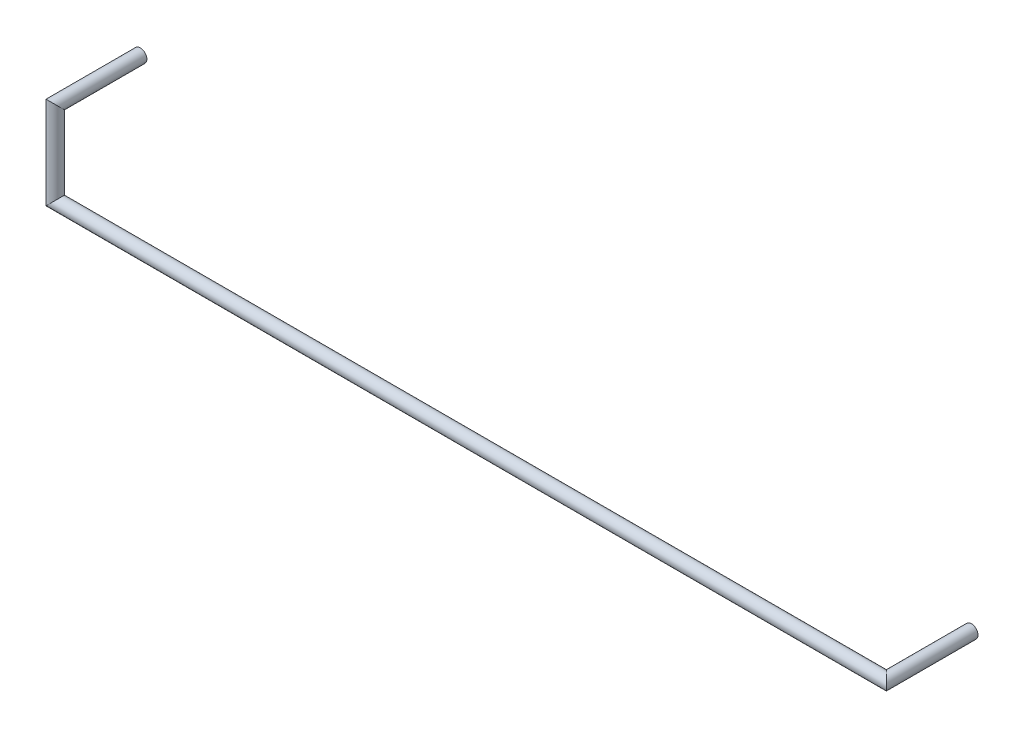
from build123d import *

# Parameters (mm, degrees)
SWEEP1_PROFILE_R = 0.2


with BuildPart() as part:
    # Sweep1: sweep along a curve in space
    with BuildLine() as sweep1_path:
        Line((0, 0, 0), (0, 0, 2.6))
        Line((0, 0, 2.6), (0, -2.54, 2.6))
        Line((0, -2.54, 2.6), (25.4, -2.54, 2.6))
        Line((25.4, -2.54, 2.6), (25.4, -2.54, 0))
    # Sweep1 profile (on start of the path) → Sweep1 (sweep)
    with BuildSketch(Plane.XY):
        Circle(SWEEP1_PROFILE_R)
    sweep(path=sweep1_path.line, transition=Transition.RIGHT)


solid = part.part
